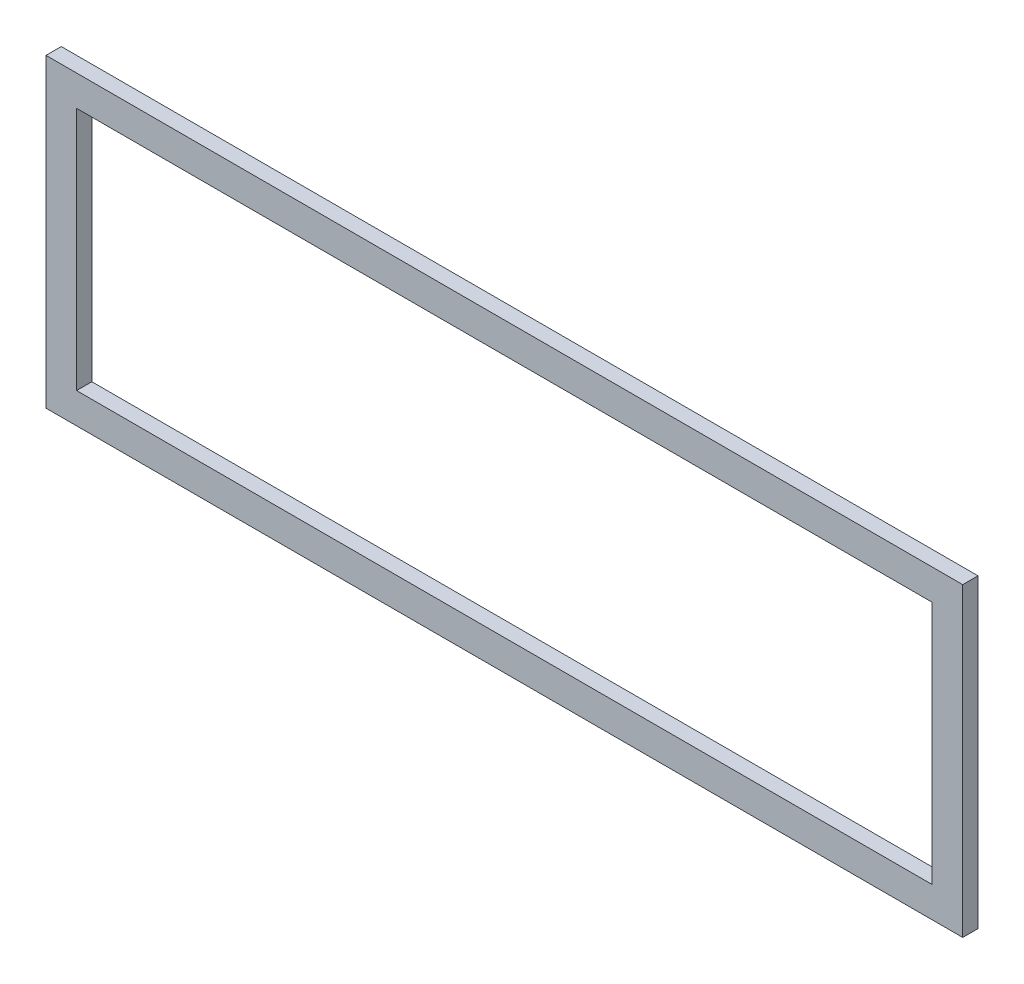
from build123d import *

# Parameters (mm, degrees)
SKETCH1_W           = 300
SKETCH1_H           = 100
SKETCH1_W_2         = 280
SKETCH1_H_2         = 80
BOSS_EXTRUDE1_DEPTH = 2.5


with BuildPart() as part:
    # Sketch1 → Boss-Extrude1 (new body, symmetric)
    with BuildSketch(Plane.XY):
        Rectangle(SKETCH1_W, SKETCH1_H)
        Rectangle(SKETCH1_W_2, SKETCH1_H_2, mode=Mode.SUBTRACT)
    extrude(amount=BOSS_EXTRUDE1_DEPTH, both=True)


solid = part.part
